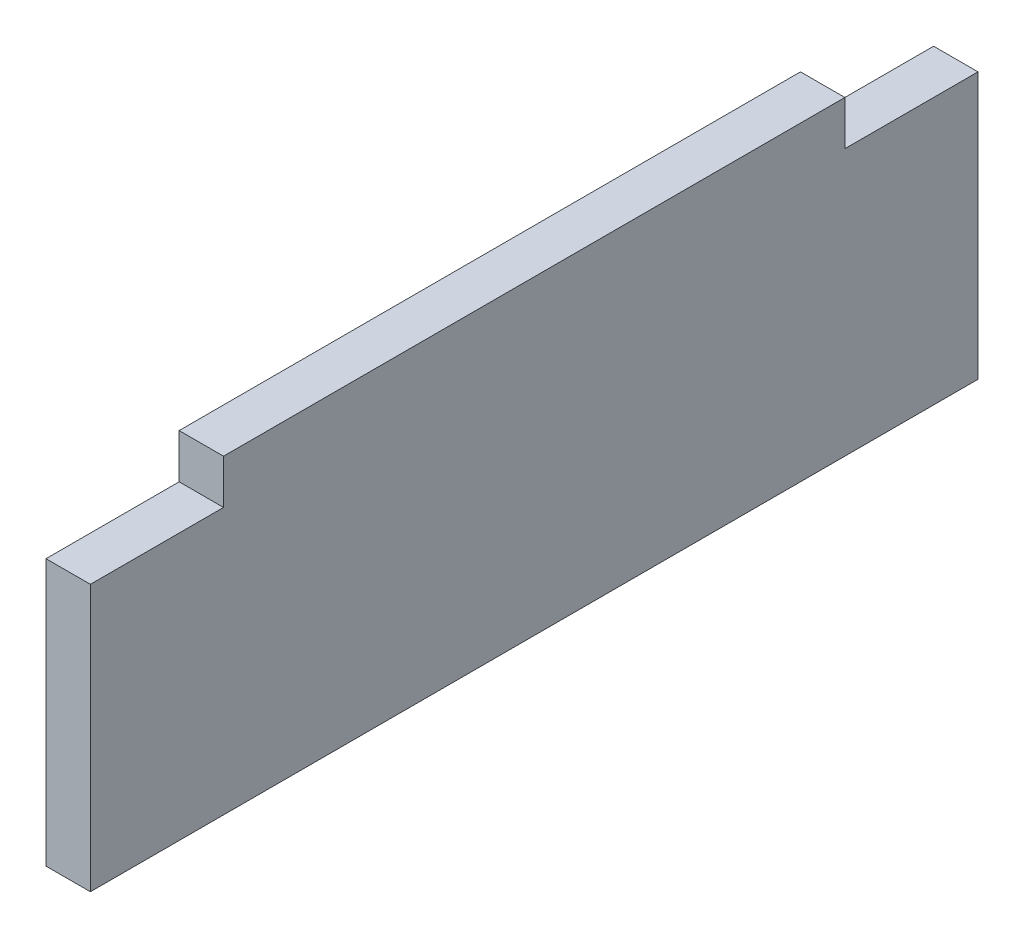
from build123d import *

# Parameters (mm, degrees)
BOSS_EXTRUDE2_DEPTH = 5


with BuildPart() as part:
    # Sketch1 → Boss-Extrude2 (new body)
    with BuildSketch(Plane(origin=(0, 0, 0), x_dir=(0, 0, -1), z_dir=(1, 0, 0))):
        Polygon((-85, 30), (-85, 35), (-15, 35), (-15, 30), (0, 30), (0, 0), (-100, 0), (-100, 30), align=None)
    extrude(amount=BOSS_EXTRUDE2_DEPTH)


solid = part.part
